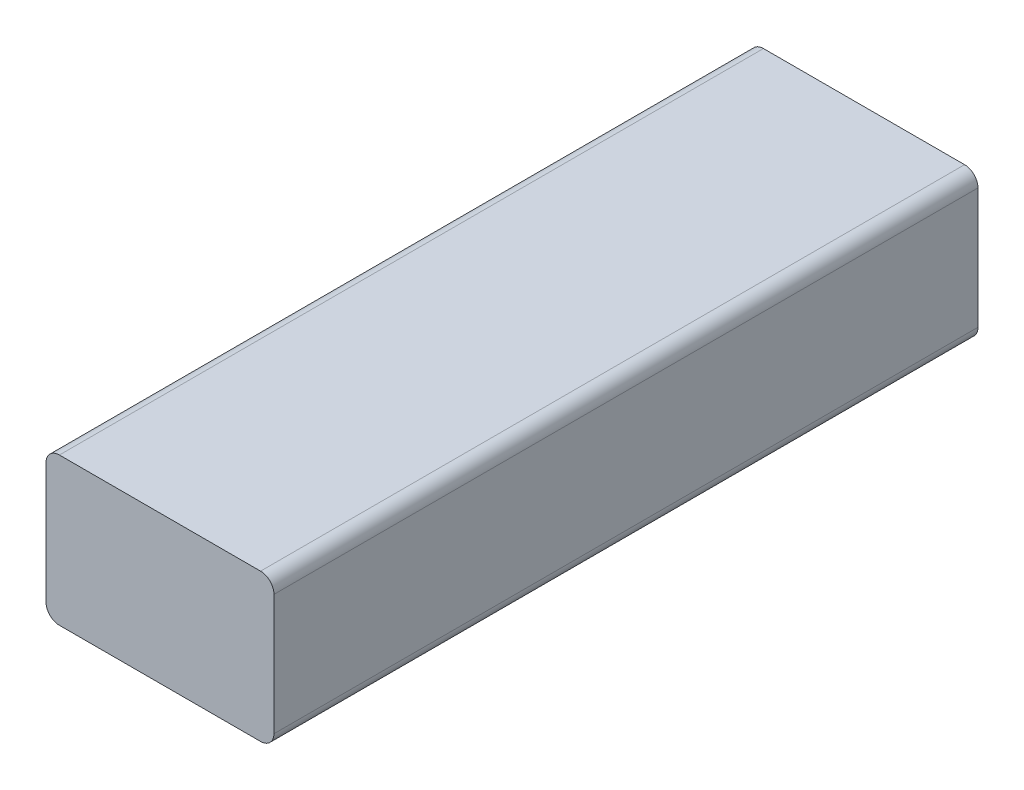
from build123d import *

# Parameters (mm, degrees)
BOSS_EXTRUDE1_DEPTH = 105


with BuildPart() as part:
    # Sketch1 → Boss-Extrude1 (new body)
    with BuildSketch(Plane.XY):
        with BuildLine():
            Line((2, 0), (32, 0))
            ThreePointArc((32, 0), (33.414213562, 0.585786438), (34, 2))
            Line((34, 2), (34, 20))
            ThreePointArc((34, 20), (33.414213562, 21.414213562), (32, 22))
            Line((32, 22), (2, 22))
            ThreePointArc((2, 22), (0.585786438, 21.414213562), (0, 20))
            Line((0, 20), (0, 2))
            ThreePointArc((0, 2), (0.585786438, 0.585786438), (2, 0))
        make_face()
    extrude(amount=BOSS_EXTRUDE1_DEPTH)


solid = part.part
